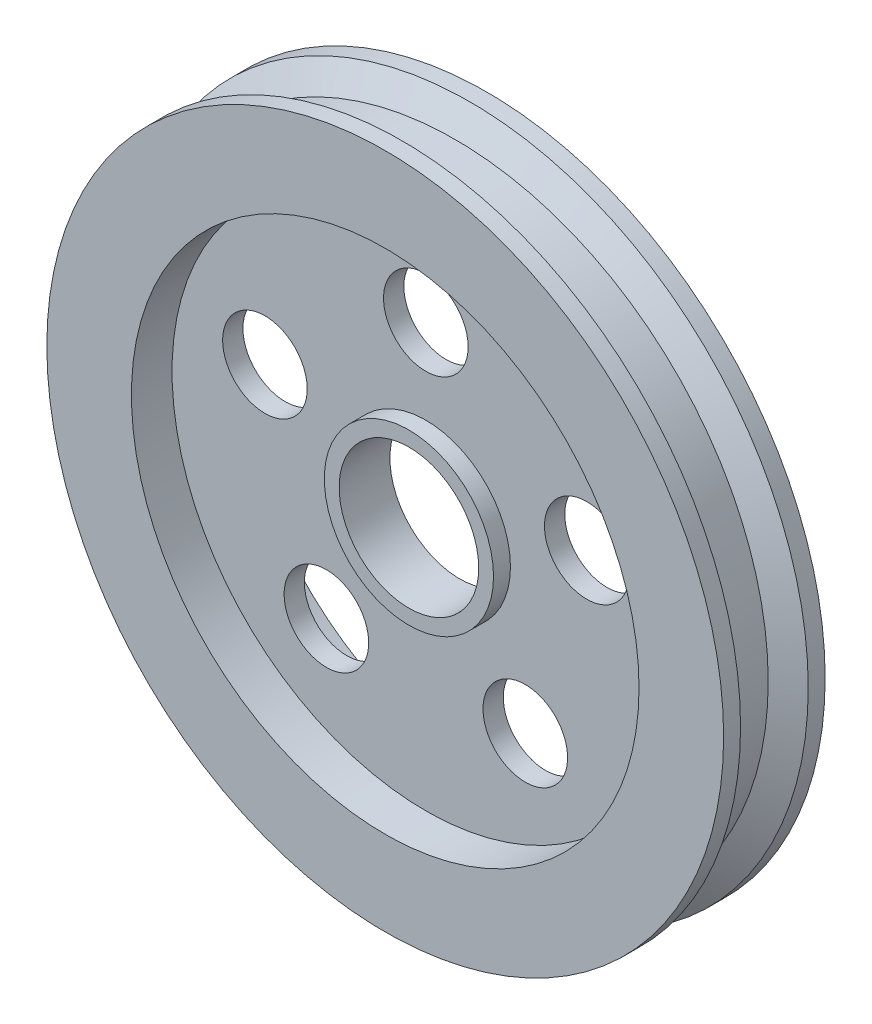
from build123d import *

# Parameters (mm, degrees)
SKETCH1_R                = 20
SKETCH1_R_2              = 4
BOSS_EXTRUDE1_DEPTH      = 3
SKETCH3_R                = 15
CUT_EXTRUDE1_DEPTH       = 2.4
SKETCH4_R                = 2.5
CUT_EXTRUDE2_DEPTH       = 4.6
CIRPATTERN1_COUNT        = 5
SKETCH14_R               = 5
BOSS_EXTRUDE3_DEPTH      = 1
BOSS_EXTRUDE3_DEPTH_BACK = 2
SKETCH16_R               = 4.125
CUT_EXTRUDE3_DEPTH       = 5.6


with BuildPart() as part:
    # Sketch1 → Boss-Extrude1 (new body, symmetric)
    with BuildSketch(Plane.XY):
        Circle(SKETCH1_R)
        Circle(SKETCH1_R_2, mode=Mode.SUBTRACT)
    extrude(amount=BOSS_EXTRUDE1_DEPTH, both=True)

    # Sketch3 → Cut-Extrude1 (cut)
    with BuildSketch(Plane.XY.offset(3)):
        Circle(SKETCH3_R)
    cut_extrude1 = extrude(amount=-CUT_EXTRUDE1_DEPTH, mode=Mode.SUBTRACT)

    # Mirror1: Cut-Extrude1 across plane
    add(cut_extrude1.mirror(Plane.XY), mode=Mode.SUBTRACT)

    # Sketch4 → Cut-Extrude2 (cut, through all)
    with BuildSketch(Plane.XY.offset(0.6)):
        with Locations((0, 10)):
            Circle(SKETCH4_R)
    cut_extrude2 = extrude(amount=-CUT_EXTRUDE2_DEPTH, mode=Mode.SUBTRACT)

    # CirPattern1: Cut-Extrude2 ×5 about axis
    cirpattern1_axis = Axis((0, 0, 0), (0, 0, 1))
    for i in range(1, CIRPATTERN1_COUNT):
        add(cut_extrude2.rotate(cirpattern1_axis, i * 360 / CIRPATTERN1_COUNT), mode=Mode.SUBTRACT)

    # Sketch5 → Cut-Revolve1 (revolve, cut)
    with BuildSketch(Plane(origin=(0, 0, 0), x_dir=(1, 0, 0), z_dir=(0, 1, 0))):
        Polygon((20, 2), (18.5, 1.133974596), (18.5, -1.133974596), (20, -2), align=None)
    revolve(axis=Axis((0, 0, 0), (0, 0, -1)), mode=Mode.SUBTRACT)

    # Sketch14 → Boss-Extrude3 (add, two sides)
    with BuildSketch(Plane.XY.offset(0.6)) as boss_extrude3_sk:
        Circle(SKETCH14_R)
    extrude(amount=BOSS_EXTRUDE3_DEPTH)
    extrude(boss_extrude3_sk.sketch, amount=-BOSS_EXTRUDE3_DEPTH_BACK)

    # Sketch16 → Cut-Extrude3 (cut, through all)
    with BuildSketch(Plane.XY.offset(1.6)):
        Circle(SKETCH16_R)
    extrude(amount=-CUT_EXTRUDE3_DEPTH, mode=Mode.SUBTRACT)


solid = part.part
